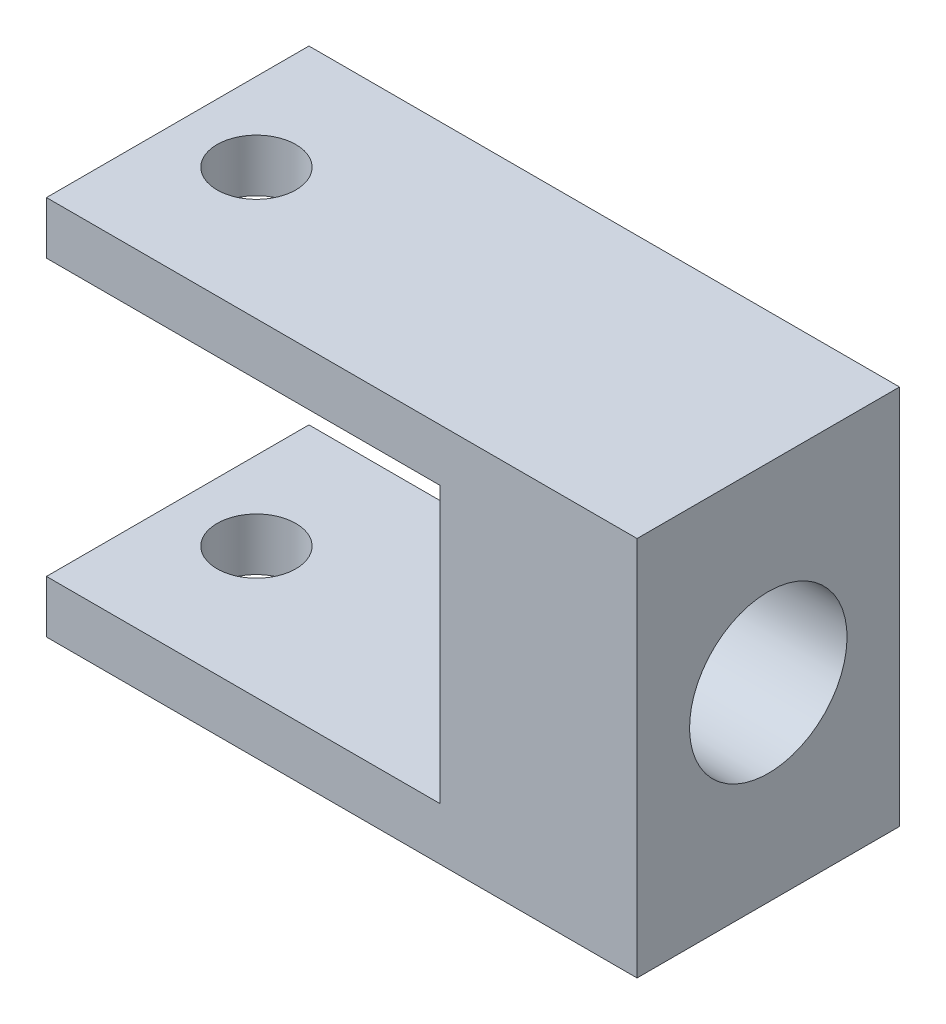
from build123d import *

# Parameters (mm, degrees)
Y_KSEKLIK_EKSTR_ZYON1_DEPTH = 20
IZIM2_R                     = 6
KES_EKSTR_ZYON1_DEPTH       = 20
IZIM3_R                     = 3
KES_EKSTR_ZYON2_DEPTH       = 40


with BuildPart() as part:
    # Çizim1 → Yükseklik-Ekstrüzyon1 (new body)
    with BuildSketch(Plane.XY):
        Polygon((-22.5, 14.5), (22.5, 14.5), (22.5, -14.5), (-22.5, -14.5), (-22.5, -10.5), (7.5, -10.5), (7.5, 10.5), (-22.5, 10.5), align=None)
    extrude(amount=Y_KSEKLIK_EKSTR_ZYON1_DEPTH)

    # Çizim2 → Kes-Ekstrüzyon1 (cut)
    with BuildSketch(Plane(origin=(22.5, 0, 0), x_dir=(0, 0, -1), z_dir=(1, 0, 0))):
        with Locations((-10, 0)):
            Circle(IZIM2_R)
    extrude(amount=-KES_EKSTR_ZYON1_DEPTH, mode=Mode.SUBTRACT)

    # Çizim3 → Kes-Ekstrüzyon2 (cut)
    with BuildSketch(Plane.XZ.offset(14.5)):
        with Locations((-16.5, 10)):
            Circle(IZIM3_R)
    extrude(amount=-KES_EKSTR_ZYON2_DEPTH, mode=Mode.SUBTRACT)


solid = part.part
